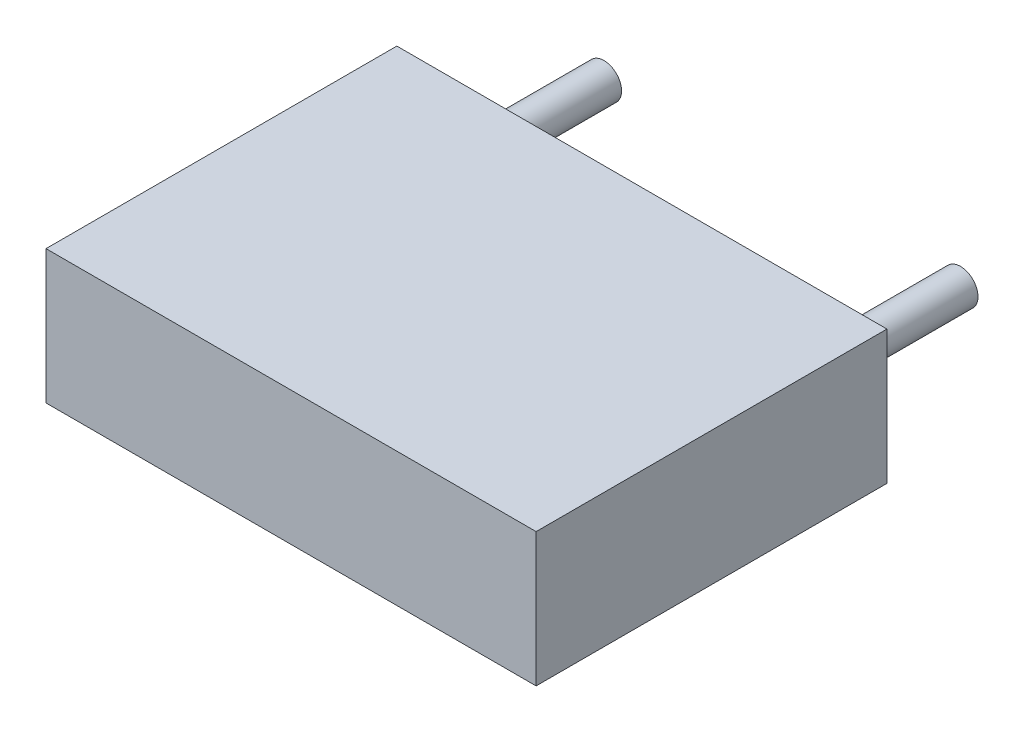
from build123d import *

# Parameters (mm, degrees)
SKETCH1_W               = 6.985
SKETCH1_H               = 1.905
COMPONENT_OUTLINE_DEPTH = 5
SKETCH2_R               = 0.25
EXTRUDE_1_DEPTH         = 2
SKETCH3_R               = 0.25
EXTRUDE_2_DEPTH         = 2


with BuildPart() as part:
    # Sketch1 → Component_Outline (new body)
    with BuildSketch(Plane.XY):
        with Locations((2.54, 0)):
            Rectangle(SKETCH1_W, SKETCH1_H)
    extrude(amount=COMPONENT_OUTLINE_DEPTH)


with BuildPart() as body_2:
    # Sketch2 → Extrude 1 (new body)
    with BuildSketch(Plane.XY):
        Circle(SKETCH2_R)
    extrude(amount=-EXTRUDE_1_DEPTH)


with BuildPart() as body_3:
    # Sketch3 → Extrude 2 (new body)
    with BuildSketch(Plane.XY):
        with Locations((5.08, 0)):
            Circle(SKETCH3_R)
    extrude(amount=-EXTRUDE_2_DEPTH)


solid = Compound([part.part, body_2.part, body_3.part])
